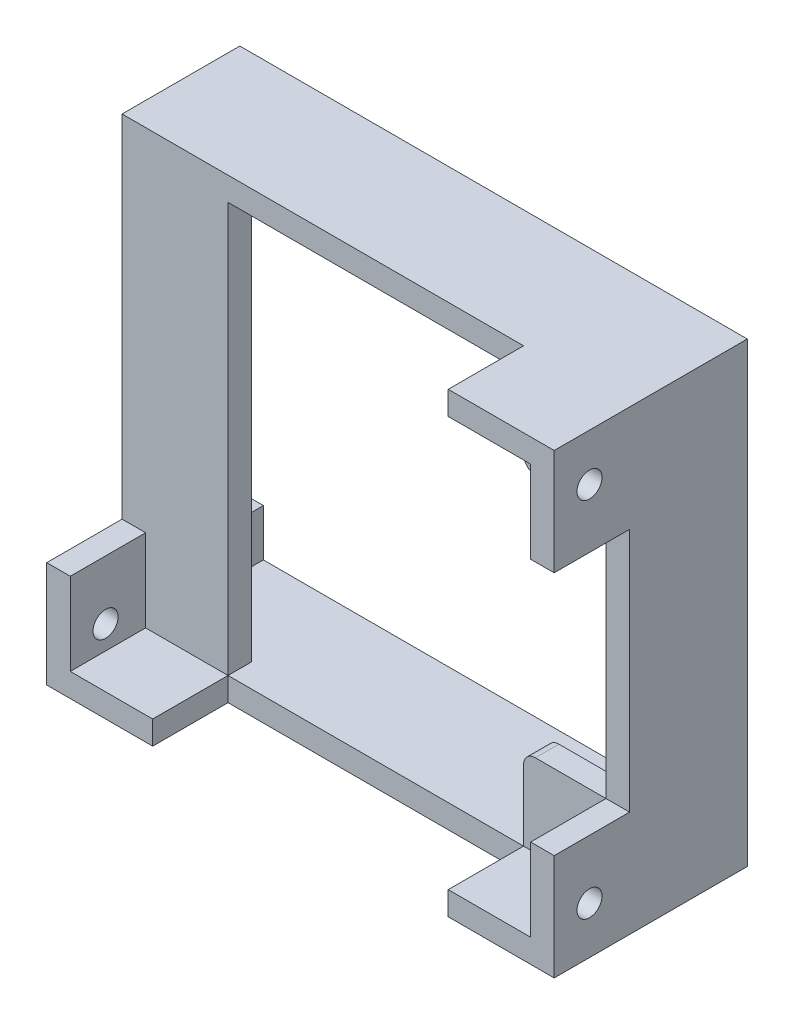
from build123d import *

# Parameters (mm, degrees)
EXTRUDE_THIN1_DEPTH = 10
SKETCH2_W           = 7
SKETCH2_H           = 7
BOSS_EXTRUDE1_DEPTH = 2
FILLET1_R           = 1
CUT_EXTRUDE1_REACH  = 45.1
SKETCH3_W           = 10
SKETCH3_H           = 28.8
SKETCH4_W           = 9
SKETCH4_H           = 28.8
BOSS_EXTRUDE2_DEPTH = 2
BOSS_EXTRUDE3_DEPTH = 6.4
SKETCH6_R           = 1.065
CUT_EXTRUDE2_DEPTH  = 44.1


with BuildPart() as part:
    # Sketch1 → Extrude-Thin1 (new body)
    with BuildSketch(Plane.XY):
        Polygon((-2, -36.8), (-2, -5), (-2, 2), (41.1, 2), (41.1, -36.8), (34.1, -36.8), align=None)
        Polygon((0, -34.8), (0, -5), (0, 0), (39.1, 0), (39.1, -34.8), (34.1, -34.8), align=None, mode=Mode.SUBTRACT)
    extrude(amount=-EXTRUDE_THIN1_DEPTH)

    # Sketch2 → Boss-Extrude1 (add)
    with BuildSketch(Plane.XY):
        with Locations((3.5, -3.5)):
            Rectangle(SKETCH2_W, SKETCH2_H)
        with Locations((35.6, -3.5)):
            Rectangle(SKETCH2_W, SKETCH2_H)
        with Locations((35.6, -31.3)):
            Rectangle(SKETCH2_W, SKETCH2_H)
        with Locations((3.5, -31.3)):
            Rectangle(SKETCH2_W, SKETCH2_H)
    extrude(amount=-BOSS_EXTRUDE1_DEPTH)

    # Fillet1
    fillet1_edges = [part.edges().sort_by_distance(p)[0] for p in [
        (7, -7, -1),
        (32.1, -7, -1),
        (32.1, -27.8, -1),
        (7, -27.8, -1),
    ]]
    fillet(fillet1_edges, radius=FILLET1_R)


with BuildPart() as body_2:
    # Mirror1: mirrored copy
    add(part.part.mirror(Plane(origin=(39.1, 0, -10), x_dir=(0, 0, 1), z_dir=(1, 0, 0))))

    # Sketch3 → Cut-Extrude1 (cut, up to next)
    with BuildSketch(Plane.ZY.offset(-37.1), mode=Mode.PRIVATE) as cut_extrude1_sk1:
        with Locations((-5, -16.4)):
            Rectangle(SKETCH3_W, SKETCH3_H)
    cut_extrude1_tool1 = extrude(cut_extrude1_sk1.sketch, amount=-CUT_EXTRUDE1_REACH, mode=Mode.PRIVATE) & body_2.part
    add(cut_extrude1_tool1.solids().sort_by_distance((37.1, -16.4, -5))[0], mode=Mode.SUBTRACT)

    # Sketch4 → Boss-Extrude2 (add)
    with BuildSketch(Plane.XY):
        with Locations((41.6, -16.4)):
            Rectangle(SKETCH4_W, SKETCH4_H)
    extrude(amount=-BOSS_EXTRUDE2_DEPTH)

    # Sketch5 → Boss-Extrude3 (add)
    with BuildSketch(Plane.XY):
        Polygon((71.2, -34.8), (71.2, -36.8), (80.2, -36.8), (80.2, -27.8), (78.2, -27.8), (78.2, -34.8), align=None)
    boss_extrude3 = extrude(amount=BOSS_EXTRUDE3_DEPTH)

    # Mirror2: Boss-Extrude3 across plane
    add(boss_extrude3.mirror(Plane.ZX.offset(-17.4)))

    # Mirror3: Boss-Extrude3 across plane
    add(boss_extrude3.mirror(Plane(origin=(58.65, 0, 0), x_dir=(0, 0, 1), z_dir=(1, 0, 0))))

    # Sketch6 → Cut-Extrude2 (cut, through all)
    with BuildSketch(Plane(origin=(80.2, 0, 0), x_dir=(0, 0, -1), z_dir=(1, 0, 0))):
        with Locations((-3.4, -32.8)):
            Circle(SKETCH6_R)
    cut_extrude2 = extrude(amount=-CUT_EXTRUDE2_DEPTH, mode=Mode.SUBTRACT)

    # Mirror4: Cut-Extrude2 across plane
    add(cut_extrude2.mirror(Plane.ZX.offset(-17.4)), mode=Mode.SUBTRACT)


solid = body_2.part
